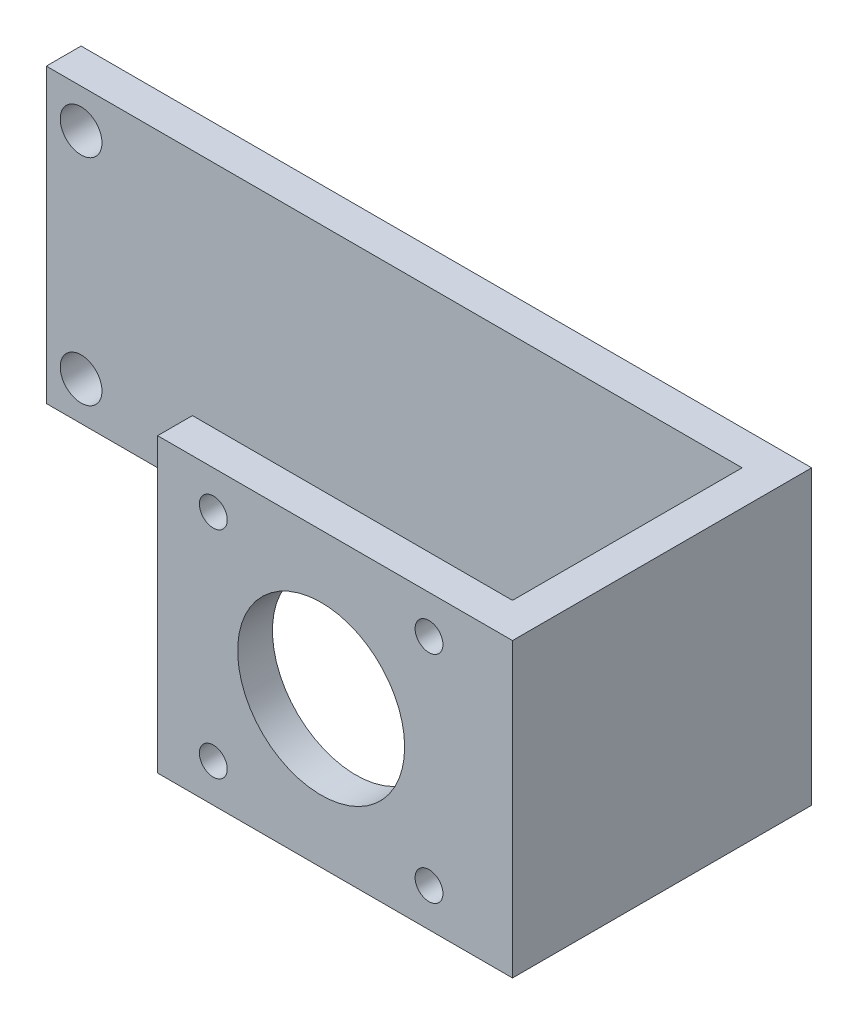
from build123d import *

# Parameters (mm, degrees)
CROQUIS1_W              = 105
CROQUIS1_H              = 42
CROQUIS1_R              = 3
SALIENTE_EXTRUIR1_DEPTH = 5
CROQUIS5_W              = 5
CROQUIS5_H              = 42
SALIENTE_EXTRUIR2_DEPTH = 38
CROQUIS8_W              = 5
CROQUIS8_H              = 42
SALIENTE_EXTRUIR3_DEPTH = 46
CROQUIS10_R             = 2
CROQUIS10_R_2           = 12
CORTAR_EXTRUIR1_DEPTH   = 5


with BuildPart() as part:
    # Croquis1 → Saliente-Extruir1 (new body)
    with BuildSketch(Plane.XY):
        Rectangle(CROQUIS1_W, CROQUIS1_H)
        with Locations((-47.5, 15.44)):
            Circle(CROQUIS1_R, mode=Mode.SUBTRACT)
        with Locations((-47.5, -15.44)):
            Circle(CROQUIS1_R, mode=Mode.SUBTRACT)
    extrude(amount=SALIENTE_EXTRUIR1_DEPTH)

    # Croquis5 → Saliente-Extruir2 (add)
    with BuildSketch(Plane.XY.offset(5)):
        with Locations((50, 0)):
            Rectangle(CROQUIS5_W, CROQUIS5_H)
    extrude(amount=SALIENTE_EXTRUIR2_DEPTH)

    # Croquis8 → Saliente-Extruir3 (add)
    with BuildSketch(Plane.ZY.offset(-47.5)):
        with Locations((40.5, 0)):
            Rectangle(CROQUIS8_W, CROQUIS8_H)
    extrude(amount=SALIENTE_EXTRUIR3_DEPTH)

    # Croquis10 → Cortar-Extruir1 (cut)
    with BuildSketch(Plane.XY.offset(43)):
        with Locations((9.5, 15.5)):
            Circle(CROQUIS10_R)
        with Locations((9.5, -15.5)):
            Circle(CROQUIS10_R)
        with Locations((40.5, -15.5)):
            Circle(CROQUIS10_R)
        with Locations((40.5, 15.5)):
            Circle(CROQUIS10_R)
        with Locations((25, 0)):
            Circle(CROQUIS10_R_2)
    extrude(amount=-CORTAR_EXTRUIR1_DEPTH, mode=Mode.SUBTRACT)


solid = part.part
